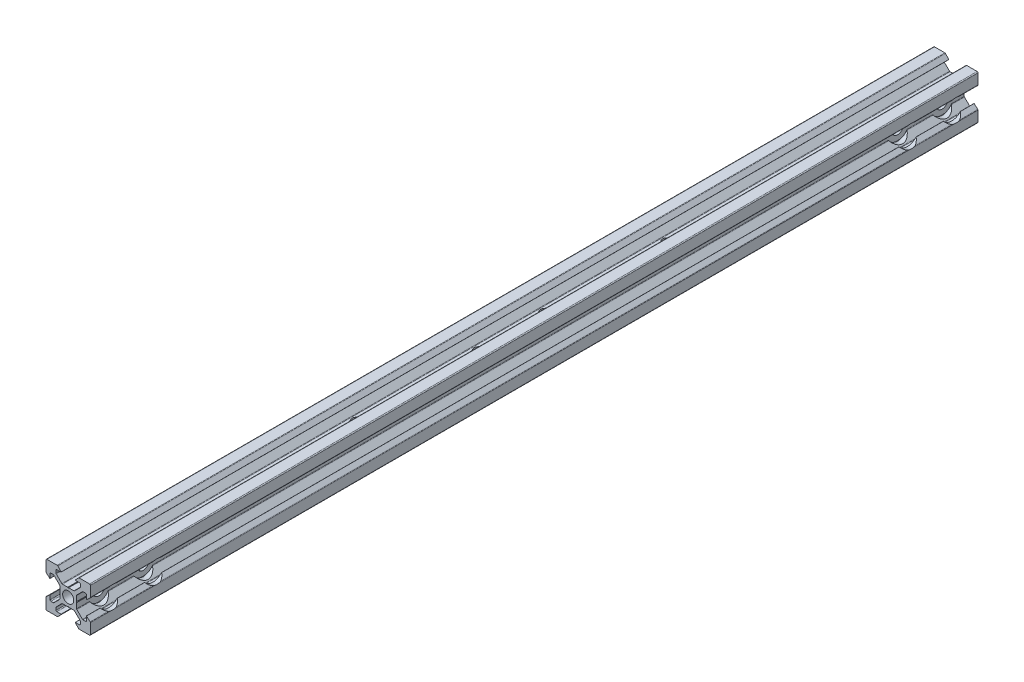
from build123d import *

# Parameters (mm, degrees)
SKETCH_1_R                  = 2
EXTRUDE_1_DEPTH             = 400
HOLE_WIZARD_5_2_5_2_1_D     = 5.2
HOLE_WIZARD_10_0_10_1_D     = 10
HOLE_WIZARD_10_0_10_1_DEPTH = 6.2
HOLE_WIZARD_M5_1_D          = 4.2
HOLE_WIZARD_5_0_5_1_D       = 5
HOLE_WIZARD_5_0_5_1_DEPTH   = 10
HOLE_WIZARD_5_0_5_1_TIP     = 1.502151548
HOLE_WIZARD_5_0_5_2_D       = 5
HOLE_WIZARD_5_0_5_2_DEPTH   = 10
HOLE_WIZARD_5_0_5_2_TIP     = 1.502151548


with BuildPart() as part:
    # 草图1 → 凸台-拉伸1 (new body)
    with BuildSketch(Plane.XY):
        with BuildLine():
            Line((0.2, 3.8), (2.573654403, 3.8))
            ThreePointArc((2.573654403, 3.8), (2.726727776, 3.830448187), (2.856497116, 3.917157288))
            Line((2.856497116, 3.917157288), (5.382842712, 6.443502884))
            ThreePointArc((5.382842712, 6.443502884), (5.469551813, 6.573272224), (5.5, 6.726345597))
            Line((5.5, 6.726345597), (5.5, 7.8))
            ThreePointArc((5.5, 7.8), (5.382842712, 8.082842712), (5.1, 8.2))
            Line((5.1, 8.2), (3.2, 8.2))
            Line((3.2, 8.2), (3.16812307, 8.273206881))
            Line((3.16812307, 8.273206881), (4.656346981, 9.872492278))
            ThreePointArc((4.656346981, 9.872492278), (4.789482474, 9.966740311), (4.949174504, 10))
            Line((4.949174504, 10), (9.6, 10))
            ThreePointArc((9.6, 10), (9.882842712, 9.882842712), (10, 9.6))
            Line((10, 9.6), (10, 4.949174504))
            ThreePointArc((10, 4.949174504), (9.966740311, 4.789482474), (9.872492278, 4.656346981))
            Line((9.872492278, 4.656346981), (8.273206881, 3.16812307))
            Line((8.273206881, 3.16812307), (8.2, 3.2))
            Line((8.2, 3.2), (8.2, 5.1))
            ThreePointArc((8.2, 5.1), (8.082842712, 5.382842712), (7.8, 5.5))
            Line((7.8, 5.5), (6.726345597, 5.5))
            ThreePointArc((6.726345597, 5.5), (6.573272224, 5.469551813), (6.443502884, 5.382842712))
            Line((6.443502884, 5.382842712), (3.917157288, 2.856497116))
            ThreePointArc((3.917157288, 2.856497116), (3.830448187, 2.726727776), (3.8, 2.573654403))
            Line((3.8, 2.573654403), (3.8, 0.2))
            Line((3.8, 0.2), (3.6, 0))
            Line((3.6, 0), (3.8, -0.2))
            Line((3.8, -0.2), (3.8, -2.573654403))
            ThreePointArc((3.8, -2.573654403), (3.830448187, -2.726727776), (3.917157288, -2.856497116))
            Line((3.917157288, -2.856497116), (6.443502885, -5.382842712))
            ThreePointArc((6.443502885, -5.382842712), (6.573272224, -5.469551813), (6.726345597, -5.5))
            Line((6.726345597, -5.5), (7.8, -5.5))
            ThreePointArc((7.8, -5.5), (8.082842713, -5.382842712), (8.2, -5.1))
            Line((8.2, -5.1), (8.2, -3.2))
            Line((8.2, -3.2), (8.273206881, -3.16812307))
            Line((8.273206881, -3.16812307), (9.872492279, -4.656346981))
            ThreePointArc((9.872492279, -4.656346981), (9.966740311, -4.789482474), (10, -4.949174504))
            Line((10, -4.949174504), (10, -9.6))
            ThreePointArc((10, -9.6), (9.882842713, -9.882842712), (9.6, -10))
            Line((9.6, -10), (4.949174504, -10))
            ThreePointArc((4.949174504, -10), (4.789482475, -9.966740311), (4.656346981, -9.872492278))
            Line((4.656346981, -9.872492278), (3.16812307, -8.273206881))
            Line((3.16812307, -8.273206881), (3.2, -8.2))
            Line((3.2, -8.2), (5.1, -8.2))
            ThreePointArc((5.1, -8.2), (5.382842713, -8.082842712), (5.5, -7.8))
            Line((5.5, -7.8), (5.5, -6.726345597))
            ThreePointArc((5.5, -6.726345597), (5.469551813, -6.573272224), (5.382842713, -6.443502884))
            Line((5.382842713, -6.443502884), (2.856497116, -3.917157288))
            ThreePointArc((2.856497116, -3.917157288), (2.726727777, -3.830448187), (2.573654404, -3.8))
            Line((2.573654404, -3.8), (0.2, -3.8))
            Line((0.2, -3.8), (0, -3.6))
            Line((0, -3.6), (-0.2, -3.8))
            Line((-0.2, -3.8), (-2.573654403, -3.8))
            ThreePointArc((-2.573654403, -3.8), (-2.726727776, -3.830448187), (-2.856497115, -3.917157288))
            Line((-2.856497115, -3.917157288), (-5.382842712, -6.443502885))
            ThreePointArc((-5.382842712, -6.443502885), (-5.469551813, -6.573272224), (-5.5, -6.726345597))
            Line((-5.5, -6.726345597), (-5.5, -7.8))
            ThreePointArc((-5.5, -7.8), (-5.382842712, -8.082842713), (-5.1, -8.2))
            Line((-5.1, -8.2), (-3.2, -8.2))
            Line((-3.2, -8.2), (-3.168123069, -8.273206881))
            Line((-3.168123069, -8.273206881), (-4.656346981, -9.872492279))
            ThreePointArc((-4.656346981, -9.872492279), (-4.789482474, -9.966740311), (-4.949174504, -10))
            Line((-4.949174504, -10), (-9.6, -10))
            ThreePointArc((-9.6, -10), (-9.882842712, -9.882842713), (-10, -9.6))
            Line((-10, -9.6), (-10, -4.949174504))
            ThreePointArc((-10, -4.949174504), (-9.966740311, -4.789482475), (-9.872492278, -4.656346981))
            Line((-9.872492278, -4.656346981), (-8.27320688, -3.16812307))
            Line((-8.27320688, -3.16812307), (-8.2, -3.2))
            Line((-8.2, -3.2), (-8.2, -5.1))
            ThreePointArc((-8.2, -5.1), (-8.082842712, -5.382842713), (-7.8, -5.5))
            Line((-7.8, -5.5), (-6.726345596, -5.5))
            ThreePointArc((-6.726345596, -5.5), (-6.573272223, -5.469551813), (-6.443502884, -5.382842713))
            Line((-6.443502884, -5.382842713), (-3.917157287, -2.856497116))
            ThreePointArc((-3.917157287, -2.856497116), (-3.830448187, -2.726727777), (-3.8, -2.573654404))
            Line((-3.8, -2.573654404), (-3.8, -0.2))
            Line((-3.8, -0.2), (-3.6, 0))
            Line((-3.6, 0), (-3.8, 0.2))
            Line((-3.8, 0.2), (-3.8, 2.573654403))
            ThreePointArc((-3.8, 2.573654403), (-3.830448187, 2.726727776), (-3.917157288, 2.856497115))
            Line((-3.917157288, 2.856497115), (-6.443502884, 5.382842712))
            ThreePointArc((-6.443502884, 5.382842712), (-6.573272224, 5.469551813), (-6.726345597, 5.5))
            Line((-6.726345597, 5.5), (-7.8, 5.5))
            ThreePointArc((-7.8, 5.5), (-8.082842712, 5.382842712), (-8.2, 5.1))
            Line((-8.2, 5.1), (-8.2, 3.2))
            Line((-8.2, 3.2), (-8.273206881, 3.168123069))
            Line((-8.273206881, 3.168123069), (-9.872492278, 4.656346981))
            ThreePointArc((-9.872492278, 4.656346981), (-9.966740311, 4.789482474), (-10, 4.949174504))
            Line((-10, 4.949174504), (-10, 9.6))
            ThreePointArc((-10, 9.6), (-9.882842712, 9.882842712), (-9.6, 10))
            Line((-9.6, 10), (-4.949174504, 10))
            ThreePointArc((-4.949174504, 10), (-4.789482474, 9.966740311), (-4.656346981, 9.872492278))
            Line((-4.656346981, 9.872492278), (-3.16812307, 8.27320688))
            Line((-3.16812307, 8.27320688), (-3.2, 8.2))
            Line((-3.2, 8.2), (-5.1, 8.2))
            ThreePointArc((-5.1, 8.2), (-5.382842712, 8.082842712), (-5.5, 7.8))
            Line((-5.5, 7.8), (-5.5, 6.726345596))
            ThreePointArc((-5.5, 6.726345596), (-5.469551813, 6.573272223), (-5.382842712, 6.443502884))
            Line((-5.382842712, 6.443502884), (-2.856497116, 3.917157287))
            ThreePointArc((-2.856497116, 3.917157287), (-2.726727776, 3.830448187), (-2.573654403, 3.8))
            Line((-2.573654403, 3.8), (-0.2, 3.8))
            Line((-0.2, 3.8), (0, 3.6))
            Line((0, 3.6), (0.2, 3.8))
        make_face()
        Circle(SKETCH_1_R, mode=Mode.SUBTRACT)
    extrude(amount=EXTRUDE_1_DEPTH)

    # Ø5.2 (5.2) 直径孔1 (through all)
    with Locations(Plane(origin=(10, 0, 0), x_dir=(0, 0, -1), z_dir=(1, 0, 0))):
        with Locations((-390, 0), (-370, 0), (-30, 0), (-10, 0)):
            Hole(HOLE_WIZARD_5_2_5_2_1_D / 2)

    # Ø10.0 (10) 直径孔1
    with Locations(Plane(origin=(10, 0, 0), x_dir=(0, 0, -1), z_dir=(1, 0, 0))):
        with Locations((-370, 0), (-390, 0), (-30, 0), (-10, 0)):
            Hole(HOLE_WIZARD_10_0_10_1_D / 2, depth=HOLE_WIZARD_10_0_10_1_DEPTH)

    # M5 螺纹孔1 (through all)
    with Locations(Plane(origin=(0, 3.8, 0), x_dir=(1, 0, 0), z_dir=(0, 1, 0))):
        with Locations((0, -270), (0, -130), (0, -185), (0, -215)):
            Hole(HOLE_WIZARD_M5_1_D / 2)

    # Ø5.0 (5) 直径孔1
    with Locations(Plane.XY.offset(400)):
        with Locations((0, 0)):
            Hole(HOLE_WIZARD_5_0_5_1_D / 2, depth=HOLE_WIZARD_5_0_5_1_DEPTH)
            with Locations((0, 0, -(HOLE_WIZARD_5_0_5_1_DEPTH + HOLE_WIZARD_5_0_5_1_TIP / 2))):  # 118° drill point
                Cone(0, HOLE_WIZARD_5_0_5_1_D / 2, HOLE_WIZARD_5_0_5_1_TIP, mode=Mode.SUBTRACT)

    # Ø5.0 (5) 直径孔2
    with Locations(Plane(origin=(0, 0, 0), x_dir=(-1, 0, 0), z_dir=(0, 0, -1))):
        with Locations((0, 0)):
            Hole(HOLE_WIZARD_5_0_5_2_D / 2, depth=HOLE_WIZARD_5_0_5_2_DEPTH)
            with Locations((0, 0, -(HOLE_WIZARD_5_0_5_2_DEPTH + HOLE_WIZARD_5_0_5_2_TIP / 2))):  # 118° drill point
                Cone(0, HOLE_WIZARD_5_0_5_2_D / 2, HOLE_WIZARD_5_0_5_2_TIP, mode=Mode.SUBTRACT)


solid = part.part
